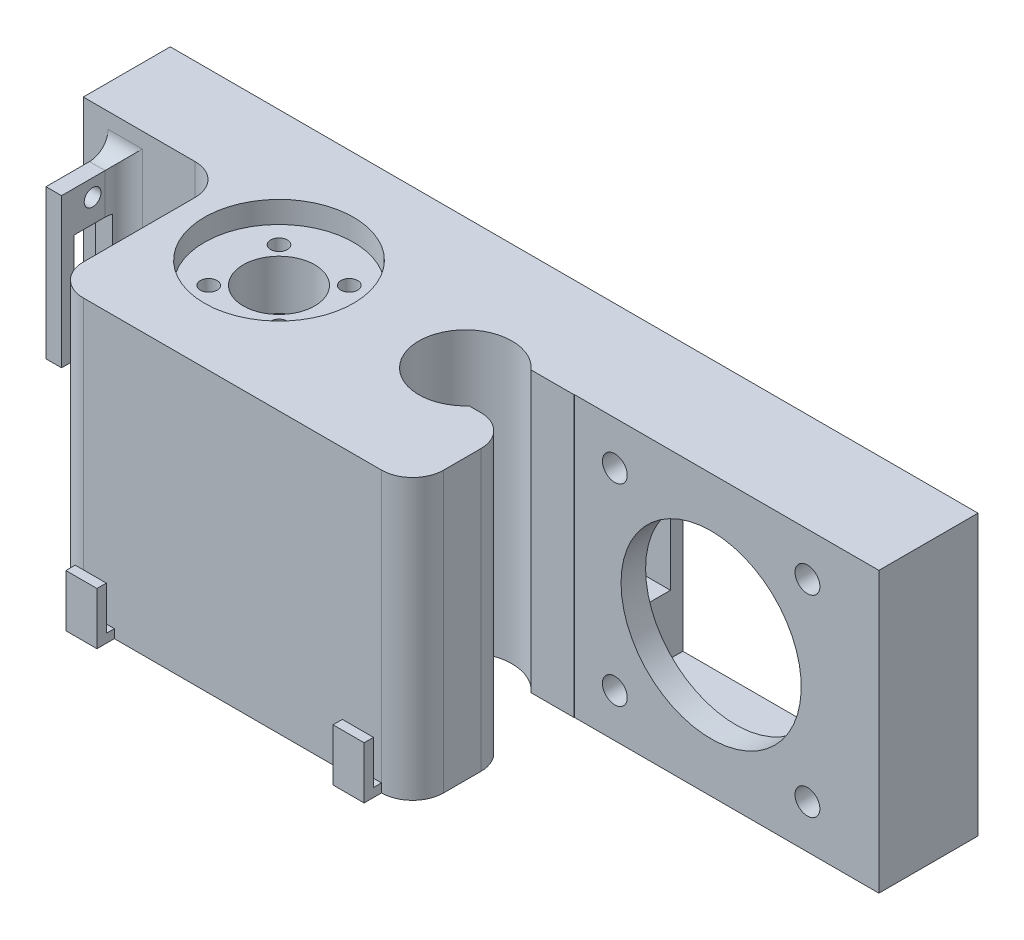
from build123d import *

# Parameters (mm, degrees)
SKETCH1_W           = 130
SKETCH1_H           = 45
BOSS_EXTRUDE1_DEPTH = 42
SKETCH2_W           = 10
SKETCH2_H           = 22
CUT_EXTRUDE1_DEPTH  = 115
SKETCH3_W           = 41
SKETCH3_H           = 41
CUT_EXTRUDE2_DEPTH  = 12
CUT_EXTRUDE3_START  = -26.05
SKETCH5_W           = 49
SKETCH5_H           = 45
CUT_EXTRUDE3_DEPTH  = 26.05
SKETCH6_R           = 2
CUT_EXTRUDE4_DEPTH  = 43
SKETCH7_R           = 12
CUT_EXTRUDE5_DEPTH  = 3.5
SKETCH8_R           = 7.5
CUT_EXTRUDE6_DEPTH  = 46
SKETCH10_W          = 23
SKETCH10_H          = 28
CUT_EXTRUDE7_DEPTH  = 46
FILLET1_R           = 5
SKETCH11_R          = 5.75
CUT_EXTRUDE8_DEPTH  = 42.5
SKETCH12_R          = 1.35
CUT_EXTRUDE9_DEPTH  = 20
SKETCH14_R          = 1.75
CUT_EXTRUDE11_DEPTH = 12
SKETCH15_W          = 32.462008986
SKETCH15_H          = 10
CUT_EXTRUDE12_DEPTH = 46
FILLET2_R           = 5
FILLET3_R           = 5
SKETCH16_R          = 12.5
CUT_EXTRUDE13_DEPTH = 33.5
SKETCH17_W          = 2.5
SKETCH17_H          = 24
BOSS_EXTRUDE2_DEPTH = 10
SKETCH18_R          = 1.35
CUT_EXTRUDE14_DEPTH = 10
FILLET4_R           = 3
FILLET5_R           = 3
SKETCH20_W          = 5
SKETCH20_H          = 1.4
BOSS_EXTRUDE3_DEPTH = 2.8
SKETCH22_W          = 5
SKETCH22_H          = 1.4
BOSS_EXTRUDE4_DEPTH = 2.8
SKETCH25_W          = 1.5
SKETCH25_H          = 5
SKETCH25_W_2        = 5
SKETCH25_H_2        = 1.5
BOSS_EXTRUDE5_DEPTH = 7
SKETCH26_R          = 14.5
CUT_EXTRUDE15_DEPTH = 10
SKETCH27_W          = 6
SKETCH27_H          = 11
CUT_EXTRUDE16_DEPTH = 10


with BuildPart() as part:
    # Sketch1 → Boss-Extrude1 (new body)
    with BuildSketch(Plane.XY):
        with Locations((65, 22.5)):
            Rectangle(SKETCH1_W, SKETCH1_H)
    extrude(amount=BOSS_EXTRUDE1_DEPTH)

    # Sketch2 → Cut-Extrude1 (cut)
    with BuildSketch(Plane.ZY):
        with Locations((7, 22.5)):
            Rectangle(SKETCH2_W, SKETCH2_H)
    extrude(amount=-CUT_EXTRUDE1_DEPTH, mode=Mode.SUBTRACT)

    # Sketch3 → Cut-Extrude2 (cut)
    with BuildSketch(Plane(origin=(0, 0, 0), x_dir=(-1, 0, 0), z_dir=(0, 0, -1))):
        with Locations((-103, 22.5)):
            Rectangle(SKETCH3_W, SKETCH3_H)
    extrude(amount=-CUT_EXTRUDE2_DEPTH, mode=Mode.SUBTRACT)

    # Sketch5 → Cut-Extrude3 (cut)
    with BuildSketch(Plane.XY.offset(42).offset(CUT_EXTRUDE3_START)):
        with Locations((105.5, 22.5)):
            Rectangle(SKETCH5_W, SKETCH5_H)
    extrude(amount=CUT_EXTRUDE3_DEPTH, mode=Mode.SUBTRACT)

    # Sketch6 → Cut-Extrude4 (cut, through all)
    with BuildSketch(Plane(origin=(0, 0, 0), x_dir=(-1, 0, 0), z_dir=(0, 0, -1))):
        with Locations((-118.5, 38)):
            Circle(SKETCH6_R)
        with Locations((-87.5, 38)):
            Circle(SKETCH6_R)
        with Locations((-87.5, 7)):
            Circle(SKETCH6_R)
        with Locations((-118.5, 7)):
            Circle(SKETCH6_R)
    extrude(amount=-CUT_EXTRUDE4_DEPTH, mode=Mode.SUBTRACT)

    # Sketch7 → Cut-Extrude5 (cut)
    with BuildSketch(Plane(origin=(0, 45, 0), x_dir=(1, 0, 0), z_dir=(0, 1, 0))):
        with Locations((38.5, -21)):
            Circle(SKETCH7_R)
    extrude(amount=-CUT_EXTRUDE5_DEPTH, mode=Mode.SUBTRACT)

    # Sketch8 → Cut-Extrude6 (cut, through all)
    with BuildSketch(Plane(origin=(0, 45, 0), x_dir=(1, 0, 0), z_dir=(0, 1, 0))):
        with Locations((68.5, -21)):
            Circle(SKETCH8_R)
    extrude(amount=-CUT_EXTRUDE6_DEPTH, mode=Mode.SUBTRACT)

    # Sketch10 → Cut-Extrude7 (cut, through all)
    with BuildSketch(Plane(origin=(0, 45, 0), x_dir=(1, 0, 0), z_dir=(0, 1, 0))):
        with Locations((11.5, -28)):
            Rectangle(SKETCH10_W, SKETCH10_H)
    extrude(amount=-CUT_EXTRUDE7_DEPTH, mode=Mode.SUBTRACT)

    # Fillet1
    fillet1_edges = [part.edges().sort_by_distance(p)[0] for p in [
        (23, 22.5, 42),
        (81, 22.5, 42),
    ]]
    fillet(fillet1_edges, radius=FILLET1_R)

    # Sketch11 → Cut-Extrude8 (cut, through all)
    with BuildSketch(Plane(origin=(0, 41.5, 0), x_dir=(1, 0, 0), z_dir=(0, 1, 0))):
        with Locations((38.5, -21)):
            Circle(SKETCH11_R)
    extrude(amount=-CUT_EXTRUDE8_DEPTH, mode=Mode.SUBTRACT)

    # Sketch12 → Cut-Extrude9 (cut)
    with BuildSketch(Plane(origin=(0, 41.5, 0), x_dir=(1, 0, 0), z_dir=(0, 1, 0))):
        with Locations((32.843145751, -15.343145751)):
            Circle(SKETCH12_R)
        with Locations((44.156854249, -15.343145751)):
            Circle(SKETCH12_R)
        with Locations((44.156854249, -26.656854249)):
            Circle(SKETCH12_R)
        with Locations((32.843145751, -26.656854249)):
            Circle(SKETCH12_R)
    extrude(amount=-CUT_EXTRUDE9_DEPTH, mode=Mode.SUBTRACT)

    # Sketch14 → Cut-Extrude11 (cut)
    with BuildSketch(Plane(origin=(0, 0, 0), x_dir=(-1, 0, 0), z_dir=(0, 0, -1))):
        with Locations((-75, 37.5)):
            Circle(SKETCH14_R)
        with Locations((-15, 37.5)):
            Circle(SKETCH14_R)
        with Locations((-15, 7.5)):
            Circle(SKETCH14_R)
        with Locations((-75, 7.5)):
            Circle(SKETCH14_R)
    extrude(amount=-CUT_EXTRUDE11_DEPTH, mode=Mode.SUBTRACT)

    # Sketch15 → Cut-Extrude12 (cut, through all)
    with BuildSketch(Plane(origin=(0, 45, 0), x_dir=(1, 0, 0), z_dir=(0, 1, 0))):
        with Locations((82.343987658, -21)):
            Rectangle(SKETCH15_W, SKETCH15_H)
    extrude(amount=-CUT_EXTRUDE12_DEPTH, mode=Mode.SUBTRACT)

    # Fillet2
    fillet2_edges = [part.edges().sort_by_distance(p)[0] for p in [
        (81, 22.5, 26),
    ]]
    fillet(fillet2_edges, radius=FILLET2_R)

    # Fillet3
    fillet3_edges = [part.edges().sort_by_distance(p)[0] for p in [
        (23, 22.5, 14),
    ]]
    fillet(fillet3_edges, radius=FILLET3_R)

    # Sketch16 → Cut-Extrude13 (cut)
    with BuildSketch(Plane.XZ):
        with Locations((38.5, 21)):
            Circle(SKETCH16_R)
    extrude(amount=-CUT_EXTRUDE13_DEPTH, mode=Mode.SUBTRACT)

    # Sketch17 → Boss-Extrude2 (add)
    with BuildSketch(Plane.XY.offset(14)):
        with Locations((5.25, 27.5)):
            Rectangle(SKETCH17_W, SKETCH17_H)
    extrude(amount=BOSS_EXTRUDE2_DEPTH)

    # Sketch18 → Cut-Extrude14 (cut)
    with BuildSketch(Plane.ZY.offset(-4)):
        with Locations((19, 36.775)):
            Circle(SKETCH18_R)
        with Locations((19, 17.725)):
            Circle(SKETCH18_R)
    extrude(amount=-CUT_EXTRUDE14_DEPTH, mode=Mode.SUBTRACT)

    # Fillet4
    fillet4_edges = [part.edges().sort_by_distance(p)[0] for p in [
        (6.5, 27.5, 14),
    ]]
    fillet(fillet4_edges, radius=FILLET4_R)

    # Fillet5
    fillet5_edges = [part.edges().sort_by_distance(p)[0] for p in [
        (8, 39.5, 14),
        (8, 15.5, 14),
    ]]
    fillet(fillet5_edges, radius=FILLET5_R)

    # Sketch20 → Boss-Extrude3 (add)
    with BuildSketch(Plane.XY.offset(42)):
        with Locations((30.5, 0.7)):
            Rectangle(SKETCH20_W, SKETCH20_H)
        with Locations((73.5, 0.7)):
            Rectangle(SKETCH20_W, SKETCH20_H)
    extrude(amount=BOSS_EXTRUDE3_DEPTH)

    # Sketch22 → Boss-Extrude4 (add)
    with BuildSketch(Plane.ZY.offset(-23)):
        with Locations((28, 0.7)):
            Rectangle(SKETCH22_W, SKETCH22_H)
    extrude(amount=BOSS_EXTRUDE4_DEPTH)

    # Sketch25 → Boss-Extrude5 (add)
    with BuildSketch(Plane(origin=(0, 1.4, 0), x_dir=(1, 0, 0), z_dir=(0, 1, 0))):
        with Locations((20.95, -28)):
            Rectangle(SKETCH25_W, SKETCH25_H)
        with Locations((73.5, -44.05)):
            Rectangle(SKETCH25_W_2, SKETCH25_H_2)
        with Locations((30.5, -44.05)):
            Rectangle(SKETCH25_W_2, SKETCH25_H_2)
    extrude(amount=BOSS_EXTRUDE5_DEPTH)

    # Sketch26 → Cut-Extrude15 (cut)
    with BuildSketch(Plane(origin=(0, 0, 12), x_dir=(-1, 0, 0), z_dir=(0, 0, -1))):
        with Locations((-103, 22.5)):
            Circle(SKETCH26_R)
    extrude(amount=-CUT_EXTRUDE15_DEPTH, mode=Mode.SUBTRACT)

    # Sketch27 → Cut-Extrude16 (cut)
    with BuildSketch(Plane.ZY.offset(-4)):
        with Locations((19, 27.5)):
            Rectangle(SKETCH27_W, SKETCH27_H)
    extrude(amount=-CUT_EXTRUDE16_DEPTH, mode=Mode.SUBTRACT)


solid = part.part
